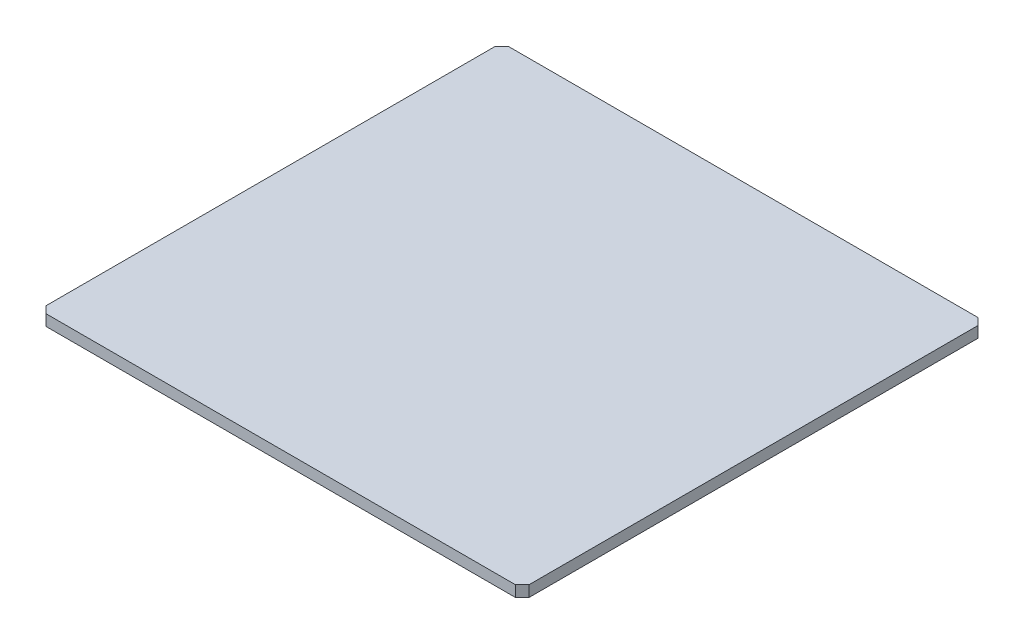
from build123d import *

# Parameters (mm, degrees)
BOSS_EXTRUDE1_DEPTH = 2.286


with BuildPart() as part:
    # Sketch1 → Boss-Extrude1 (new body)
    with BuildSketch(Plane(origin=(0, 0, 0), x_dir=(1, 0, 0), z_dir=(0, 1, 0))):
        Polygon((0.1017, 94.137486438), (1.526292523, 95.562078961), (98.473707477, 95.562078961), (99.8983, 94.137486438), (99.8983, 1.414213562), (98.473707477, -0.010378961), (1.526292523, -0.010378961), (0.1017, 1.414213562), align=None)
    extrude(amount=BOSS_EXTRUDE1_DEPTH)


solid = part.part
